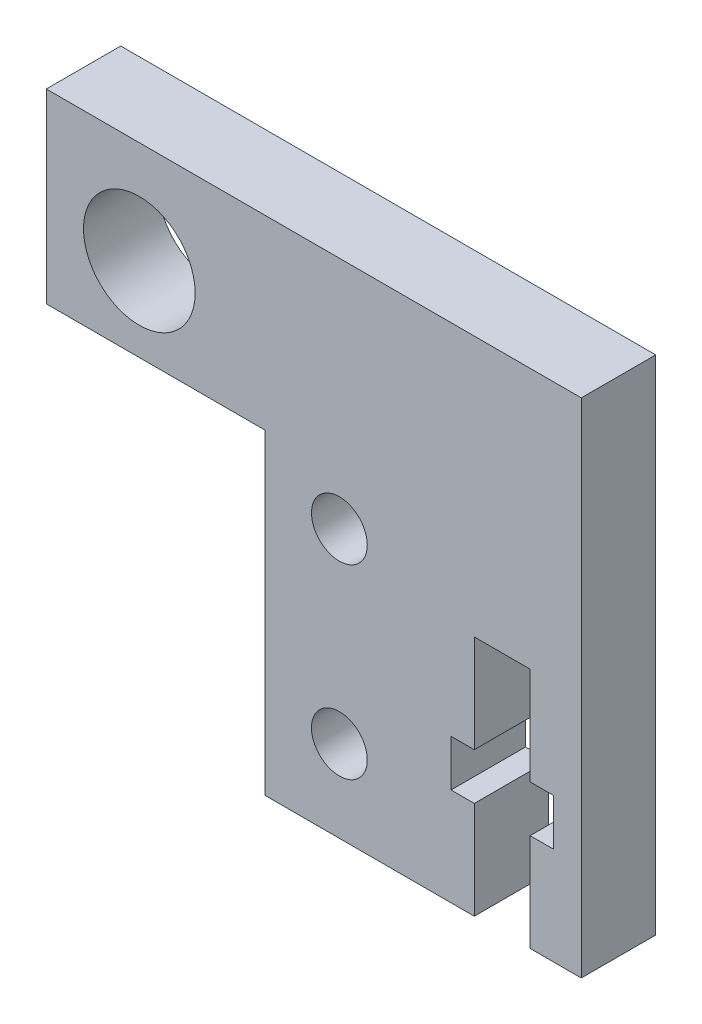
from build123d import *

# Parameters (mm, degrees)
SKETCH_1_W               = 17
SKETCH_1_H               = 27
SKETCH_1_R               = 1.5
EXTRUDE_1_DEPTH          = 4
CUT_EXTRUDE_1_DEPTH      = 1
CUT_EXTRUDE_1_DEPTH_BACK = 4
SKETCH_5_W               = 11.75
SKETCH_5_H               = 10
SKETCH_5_R               = 3
EXTRUDE_2_DEPTH          = 4


with BuildPart() as part:
    # Эскиз1 → Бобышка-Вытянуть1 (new body)
    with BuildSketch(Plane.XY):
        with Locations((8.5, 13.5)):
            Rectangle(SKETCH_1_W, SKETCH_1_H)
        with Locations((4, 14.4)):
            Circle(SKETCH_1_R, mode=Mode.SUBTRACT)
        with Locations((4, 4.4)):
            Circle(SKETCH_1_R, mode=Mode.SUBTRACT)
    extrude(amount=EXTRUDE_1_DEPTH)

    # Эскиз2 → Вырез-Вытянуть1 (cut, two sides)
    with BuildSketch(Plane.XY.offset(4)) as cut_extrude_1_sk:
        Polygon((11.25, 5.25), (11.25, 0), (14.25, 0), (14.25, 5.25), (15.5, 5.25), (15.5, 7.75), (14.25, 7.75), (14.25, 13), (11.25, 13), (11.25, 7.75), (10, 7.75), (10, 5.25), align=None)
    extrude(amount=CUT_EXTRUDE_1_DEPTH, mode=Mode.SUBTRACT)
    extrude(cut_extrude_1_sk.sketch, amount=-CUT_EXTRUDE_1_DEPTH_BACK, mode=Mode.SUBTRACT)

    # Эскиз5 → Бобышка-Вытянуть2 (add)
    with BuildSketch(Plane.XY.offset(4)):
        with Locations((-5.875, 22)):
            Rectangle(SKETCH_5_W, SKETCH_5_H)
        with Locations((-6.75, 21.5)):
            Circle(SKETCH_5_R, mode=Mode.SUBTRACT)
    extrude(amount=-EXTRUDE_2_DEPTH)


solid = part.part
